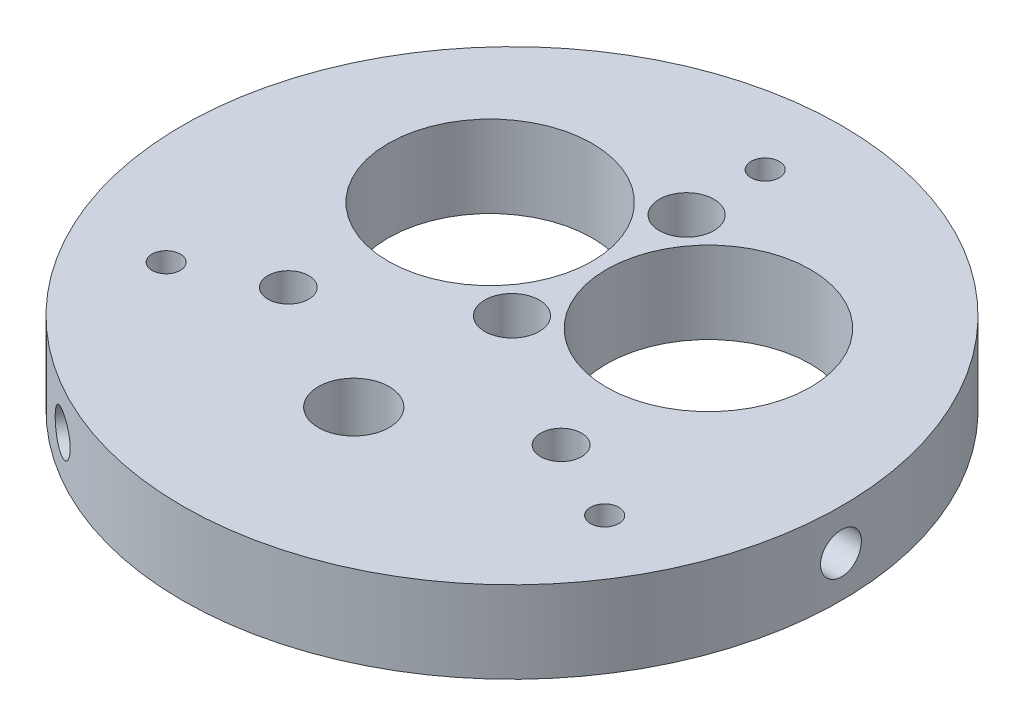
from build123d import *

# Parameters (mm, degrees)
SKETCH1_R               = 38.354
BOSS_EXTRUDE1_DEPTH     = 9.525
SKETCH2_R               = 1.651
SKETCH2_R_2             = 4.1275
SKETCH2_R_3             = 11.8745
SKETCH2_R_4             = 3.175
CUT_EXTRUDE1_DEPTH      = 56.070720506
SKETCH4_R               = 2.3749
CUT_EXTRUDE2_DEPTH      = 6.35
CIRPATTERN1_COUNT       = 3
CUT_EXTRUDE3_DEPTH      = 56.070720662
CUT_EXTRUDE3_DEPTH_BACK = 56.070720662
SKETCH5_R               = 2.38125


with BuildPart() as part:
    # Sketch1 → Boss-Extrude1 (new body)
    with BuildSketch(Plane(origin=(0, 0, 0), x_dir=(1, 0, 0), z_dir=(0, 1, 0))):
        Circle(SKETCH1_R)
    extrude(amount=BOSS_EXTRUDE1_DEPTH)

    # Sketch2 → Cut-Extrude1 (cut, through all)
    with BuildSketch(Plane(origin=(0, 9.525, 0), x_dir=(1, 0, 0), z_dir=(0, 1, 0))):
        with Locations((0, 29.464)):
            Circle(SKETCH2_R)
        with Locations((25.516572497, -14.732)):
            Circle(SKETCH2_R)
        with Locations((-25.516572497, -14.732)):
            Circle(SKETCH2_R)
        with Locations((0, -18.415)):
            Circle(SKETCH2_R_2)
        with Locations((-12.7, 10.16)):
            Circle(SKETCH2_R_3)
        with Locations((12.7, 10.16)):
            Circle(SKETCH2_R_3)
        with Locations((0, 20.32)):
            Circle(SKETCH2_R_4)
        Circle(SKETCH2_R_4)
    extrude(amount=-CUT_EXTRUDE1_DEPTH, mode=Mode.SUBTRACT)

    # Sketch4 → Cut-Extrude2 (cut)
    with BuildSketch(Plane(origin=(-19.177, 0, -33.215538337), x_dir=(0, -1, 0), z_dir=(-0.499999999999998, 0, -0.8660254037844398))):
        with Locations((-4.7625, 0)):
            Circle(SKETCH4_R)
    cut_extrude2 = extrude(amount=-CUT_EXTRUDE2_DEPTH, mode=Mode.SUBTRACT)

    # CirPattern1: Cut-Extrude2 ×3 about axis
    cirpattern1_axis = Axis((0, 10.00125, 0), (0, -1, 0))
    for i in range(1, CIRPATTERN1_COUNT):
        add(cut_extrude2.rotate(cirpattern1_axis, i * 360 / CIRPATTERN1_COUNT), mode=Mode.SUBTRACT)

    # Sketch5 → Cut-Extrude3 (cut, two sides: drawn at the far end of the back side and taken through both)
    with BuildSketch(Plane(origin=(0, 9.525, 0), x_dir=(1, 0, 0), z_dir=(0, 1, 0)).offset(-CUT_EXTRUDE3_DEPTH_BACK)):
        with Locations((-15.875, -10.16)):
            Circle(SKETCH5_R)
        with Locations((15.875, -10.16)):
            Circle(SKETCH5_R)
    extrude(amount=CUT_EXTRUDE3_DEPTH + CUT_EXTRUDE3_DEPTH_BACK, mode=Mode.SUBTRACT)


solid = part.part
